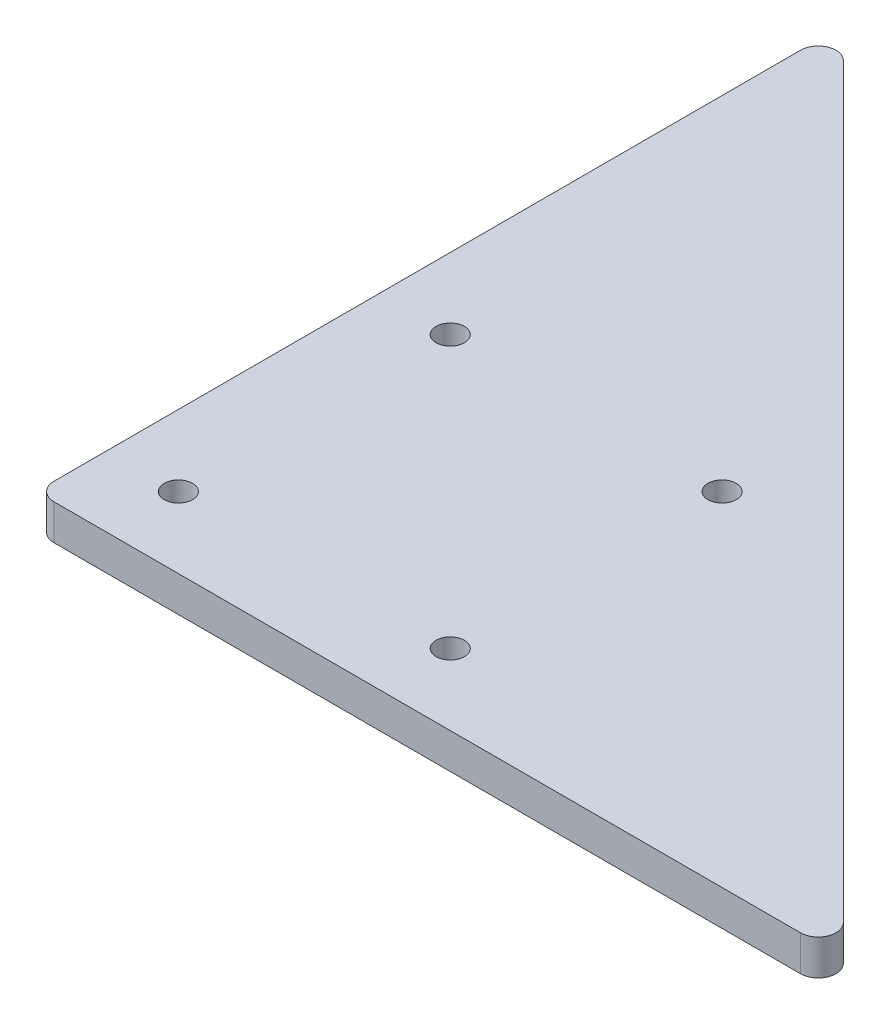
from build123d import *

# Parameters (mm, degrees)
SKETCH1_R           = 2.4
BOSS_EXTRUDE1_DEPTH = 6


with BuildPart() as part:
    # Sketch1 → Boss-Extrude1 (new body)
    with BuildSketch(Plane(origin=(0, 0, 0), x_dir=(1, 0, 0), z_dir=(0, 1, 0))):
        with BuildLine():
            ThreePointArc((-35, -32), (-34.121320344, -34.121320344), (-32, -35))
            Line((-32, -35), (94.221825407, -35))
            ThreePointArc((94.221825407, -35), (96.993464004, -33.148050297), (96.343145751, -29.878679656))
            Line((96.343145751, -29.878679656), (-29.878679656, 96.343145751))
            ThreePointArc((-29.878679656, 96.343145751), (-33.148050297, 96.993464004), (-35, 94.221825407))
            Line((-35, 94.221825407), (-35, -32))
        make_face()
        with Locations((-22.980970389, -22.980970389)):
            Circle(SKETCH1_R, mode=Mode.SUBTRACT)
        with Locations((22.980970389, -22.980970389)):
            Circle(SKETCH1_R, mode=Mode.SUBTRACT)
        with Locations((-22.980970389, 22.980970389)):
            Circle(SKETCH1_R, mode=Mode.SUBTRACT)
        with Locations((22.980970389, 22.980970389)):
            Circle(SKETCH1_R, mode=Mode.SUBTRACT)
    extrude(amount=BOSS_EXTRUDE1_DEPTH)


solid = part.part
